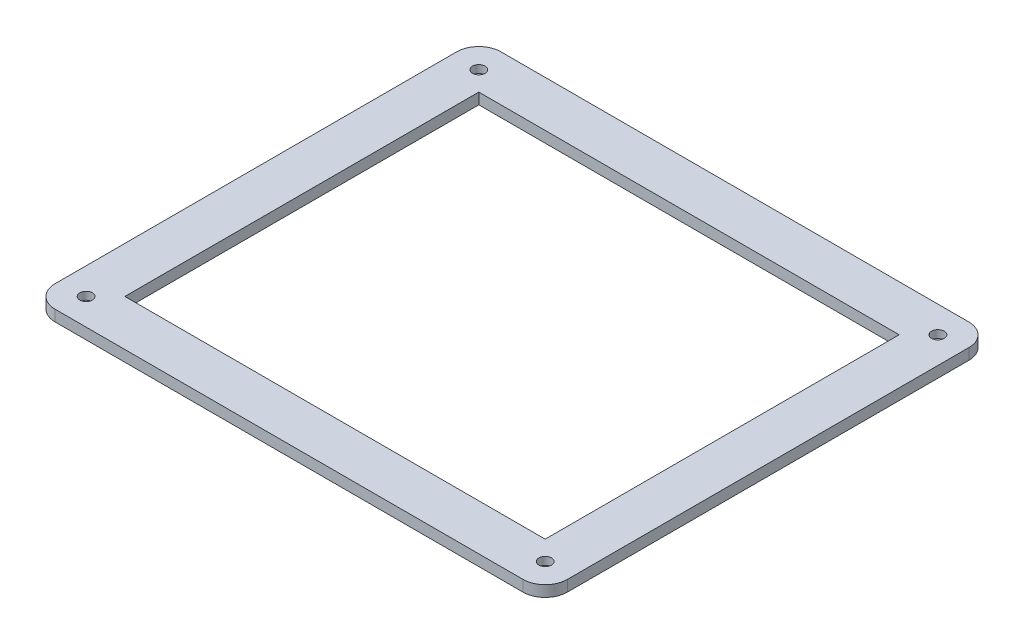
from build123d import *

# Parameters (mm, degrees)
SKETCH1_W               = 231.4
SKETCH1_H               = 201.4
SKETCH1_W_2             = 189.9
SKETCH1_H_2             = 159.9
BOSS_EXTRUDE1_DEPTH     = 5
FILLET1_R               = 10
SKETCH2_R               = 5.85
BOSS_EXTRUDE2_DEPTH     = 2.5
SKETCH3_R               = 1.55
CUT_EXTRUDE1_DEPTH      = 7.5
SKETCH4_R               = 2.85
CUT_EXTRUDE2_DEPTH      = 3.5
MIRROR4_COPY_1_SKETCH_R = 5.85
MIRROR4_COPY_1_DEPTH    = 2.5
MIRROR4_COPY_2_SKETCH_R = 1.55
MIRROR4_COPY_2_DEPTH    = 7.5
MIRROR4_COPY_3_SKETCH_R = 2.85
MIRROR4_COPY_3_DEPTH    = 3.5


with BuildPart() as part:
    # Sketch1 → Boss-Extrude1 (new body)
    with BuildSketch(Plane(origin=(0, 0, 0), x_dir=(1, 0, 0), z_dir=(0, 1, 0))):
        Rectangle(SKETCH1_W, SKETCH1_H)
        Rectangle(SKETCH1_W_2, SKETCH1_H_2, mode=Mode.SUBTRACT)
    extrude(amount=BOSS_EXTRUDE1_DEPTH)

    # Fillet1
    fillet1_edges = [part.edges().sort_by_distance(p)[0] for p in [
        (-115.7, 2.5, -100.7),
        (115.7, 2.5, -100.7),
        (115.7, 2.5, 100.7),
        (-115.7, 2.5, 100.7),
    ]]
    fillet(fillet1_edges, radius=FILLET1_R)

    # Sketch2 → Boss-Extrude2 (add)
    with BuildSketch(Plane.XZ):
        with Locations((-103.7, 88.7)):
            Circle(SKETCH2_R)
    boss_extrude2 = extrude(amount=BOSS_EXTRUDE2_DEPTH)

    # Sketch3 → Cut-Extrude1 (cut)
    with BuildSketch(Plane(origin=(0, 5, 0), x_dir=(1, 0, 0), z_dir=(0, 1, 0))):
        with Locations((-103.7, -88.7)):
            Circle(SKETCH3_R)
    cut_extrude1 = extrude(amount=-CUT_EXTRUDE1_DEPTH, mode=Mode.SUBTRACT)

    # Sketch4 → Cut-Extrude2 (cut)
    with BuildSketch(Plane(origin=(0, 5, 0), x_dir=(1, 0, 0), z_dir=(0, 1, 0))):
        with Locations((-103.7, -88.7)):
            Circle(SKETCH4_R)
    cut_extrude2 = extrude(amount=-CUT_EXTRUDE2_DEPTH, mode=Mode.SUBTRACT)

    # Mirror3: Boss-Extrude2, Cut-Extrude1, Cut-Extrude2 across plane
    add(boss_extrude2.mirror(Plane(origin=(0, 0, 0), x_dir=(0, 0, 1), z_dir=(1, 0, 0))))
    add(cut_extrude1.mirror(Plane(origin=(0, 0, 0), x_dir=(0, 0, 1), z_dir=(1, 0, 0))), mode=Mode.SUBTRACT)
    add(cut_extrude2.mirror(Plane(origin=(0, 0, 0), x_dir=(0, 0, 1), z_dir=(1, 0, 0))), mode=Mode.SUBTRACT)

    # Mirror4: Boss-Extrude2, Cut-Extrude1, Cut-Extrude2 across plane
    add(boss_extrude2.mirror(Plane.XY))
    add(cut_extrude1.mirror(Plane.XY), mode=Mode.SUBTRACT)
    add(cut_extrude2.mirror(Plane.XY), mode=Mode.SUBTRACT)

    # Mirror4 copy 1 sketch → Mirror4 copy 1 (add)
    with BuildSketch(Plane(origin=(0, 0, 0), x_dir=(-1, 0, 0), z_dir=(0, -1, 0))):
        with Locations((-103.7, 88.7)):
            Circle(MIRROR4_COPY_1_SKETCH_R)
    extrude(amount=MIRROR4_COPY_1_DEPTH)

    # Mirror4 copy 2 sketch → Mirror4 copy 2 (cut)
    with BuildSketch(Plane(origin=(0, 5, 0), x_dir=(-1, 0, 0), z_dir=(0, 1, 0))):
        with Locations((-103.7, -88.7)):
            Circle(MIRROR4_COPY_2_SKETCH_R)
    extrude(amount=-MIRROR4_COPY_2_DEPTH, mode=Mode.SUBTRACT)

    # Mirror4 copy 3 sketch → Mirror4 copy 3 (cut)
    with BuildSketch(Plane(origin=(0, 5, 0), x_dir=(-1, 0, 0), z_dir=(0, 1, 0))):
        with Locations((-103.7, -88.7)):
            Circle(MIRROR4_COPY_3_SKETCH_R)
    extrude(amount=-MIRROR4_COPY_3_DEPTH, mode=Mode.SUBTRACT)


solid = part.part
